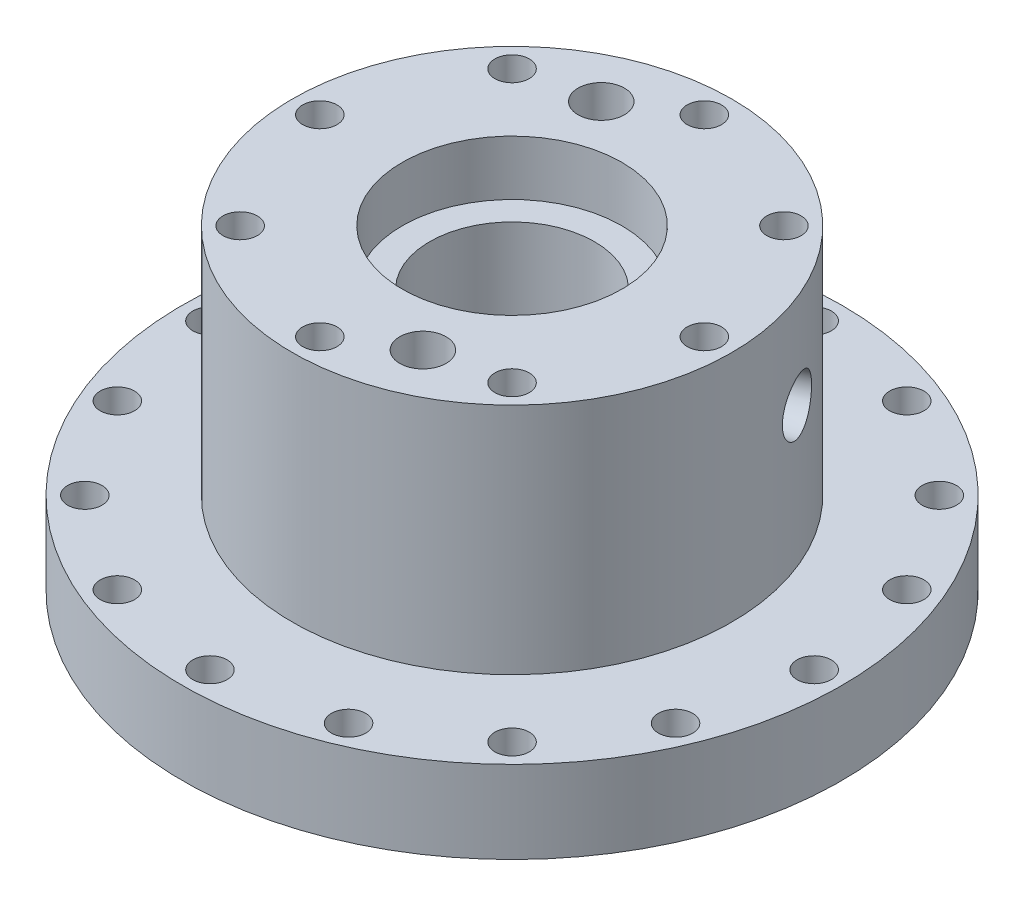
from build123d import *

# Parameters (mm, degrees)
CIRPATTERN1_COUNT = 16
CIRPATTERN2_COUNT = 8
CIRPATTERN3_COUNT = 2


with BuildPart() as part:
    # Sketch1 → Revolve1 (revolve)
    with BuildSketch(Plane.XY):
        Polygon((-76.2, 19.05), (-76.2, 0), (-42.8625, 0), (-25.4, 15.875), (-19.05, 15.875), (-19.05, 60.325), (-25.4, 60.325), (-25.4, 73.025), (-50.8, 73.025), (-50.8, 19.05), align=None)
    revolve(axis=Axis((0, 0, 0), (0, 1, 0)))

    # Sketch5 → 5_16 _0.3125_ Diameter Hole1 (revolve, cut)
    with BuildSketch(Plane(origin=(-69.85, 19.05, 0), x_dir=(0, 0, 1), z_dir=(1, 0, 0))):
        Polygon((0, 0), (0, 40.484665582), (3.96875, 38.1), (3.96875, 0), align=None)
    f_5_16_0_3125_diameter_hole1 = revolve(axis=Axis((-69.85, 25.4, 0), (0, -1, 0)), mode=Mode.SUBTRACT)

    # CirPattern1: 5_16 _0.3125_ Diameter Hole1 ×16 about axis
    cirpattern1_axis = Axis((0, 0.635, 0), (0, -1, 0))
    for i in range(1, CIRPATTERN1_COUNT):
        add(f_5_16_0_3125_diameter_hole1.rotate(cirpattern1_axis, i * 360 / CIRPATTERN1_COUNT), mode=Mode.SUBTRACT)

    # Sketch7 → 5_16 _0.3125_ Diameter Hole2 (revolve, cut)
    with BuildSketch(Plane(origin=(44.45, 73.025, 0), x_dir=(0, 0, 1), z_dir=(1, 0, 0))):
        Polygon((0, 0), (0, 27.784665582), (3.96875, 25.4), (3.96875, 0), align=None)
    f_5_16_0_3125_diameter_hole2 = revolve(axis=Axis((44.45, 79.375, 0), (0, -1, 0)), mode=Mode.SUBTRACT)

    # CirPattern2: 5_16 _0.3125_ Diameter Hole2 ×8 about axis
    cirpattern2_axis = Axis((0, 0, 0), (0, -1, 0))
    for i in range(1, CIRPATTERN2_COUNT):
        add(f_5_16_0_3125_diameter_hole2.rotate(cirpattern2_axis, i * 360 / CIRPATTERN2_COUNT), mode=Mode.SUBTRACT)

    # Sketch9 → 1_4 NPT Tapped Hole1 (revolve, cut)
    with BuildSketch(Plane(origin=(46.933080252, 50.8, -19.440318364), x_dir=(-0.38268343236509056, 0, -0.9238795325112864), z_dir=(0, 1, 0))):
        Polygon((0, 0), (0, 41.442347279), (5.5626, 38.1), (5.5626, 9.906), (5.943685794, 9.906), (6.2402847, 0), align=None)
    revolve(axis=Axis((52.799715283, 50.8, -21.87035816), (-0.9238795325112865, 0, 0.38268343236509056)), mode=Mode.SUBTRACT)

    # Sketch13 → Tap Drill for 1_2-13 Tap1 (revolve, cut)
    with BuildSketch(Plane(origin=(-14.580238773, 73.025, -35.199810189), x_dir=(0, 0, 1), z_dir=(1, 0, 0))):
        Polygon((0, 0), (0, 66.719489309), (5.35813, 63.5), (5.35813, 0), align=None)
    tap_drill_for_1_2_13_tap1 = revolve(axis=Axis((-14.580238773, 79.375, -35.199810189), (0, -1, 0)), mode=Mode.SUBTRACT)

    # CirPattern3: Tap Drill for 1_2-13 Tap1 ×2 about axis
    cirpattern3_axis = Axis((0, 0, 0), (0, -1, 0))
    for i in range(1, CIRPATTERN3_COUNT):
        add(tap_drill_for_1_2_13_tap1.rotate(cirpattern3_axis, i * 360 / CIRPATTERN3_COUNT), mode=Mode.SUBTRACT)


solid = part.part
